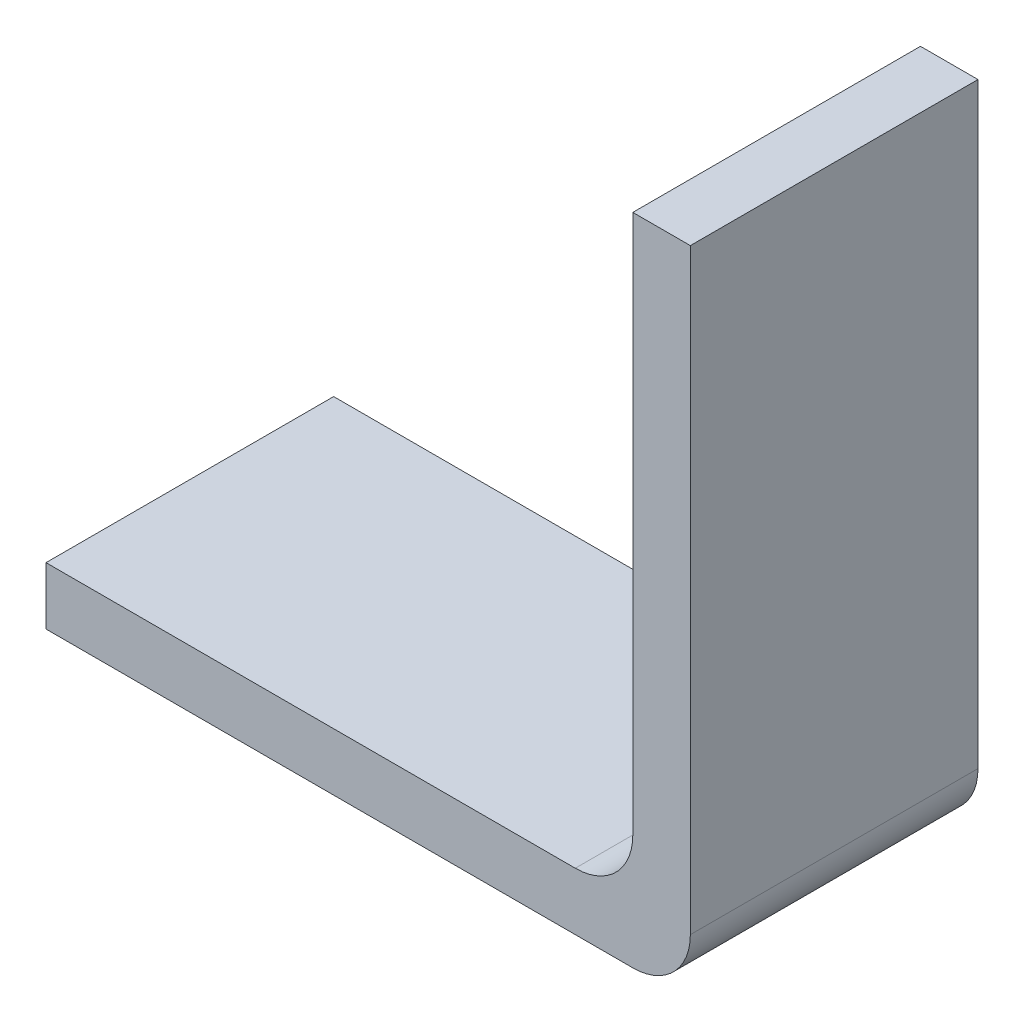
from build123d import *

# Parameters (mm, degrees)
EKSTR_ZYON_NCE2_DEPTH = 5
RADYUS1_R             = 1


with BuildPart() as part:
    # Çizim1 → Ekstrüzyon-İnce2 (new body)
    with BuildSketch(Plane.XY):
        Polygon((82.990542752, -22.308839901), (82.990542752, -33.681351263), (71.790542752, -33.681351263), (71.790542752, -32.681351263), (81.990542752, -32.681351263), (81.990542752, -22.308839901), align=None)
    extrude(amount=EKSTR_ZYON_NCE2_DEPTH)

    # Radyus1
    radyus1_edges = [part.edges().sort_by_distance(p)[0] for p in [
        (81.990542752, -32.681351263, 2.5),
        (82.990542752, -33.681351263, 2.5),
    ]]
    fillet(radyus1_edges, radius=RADYUS1_R)


solid = part.part
